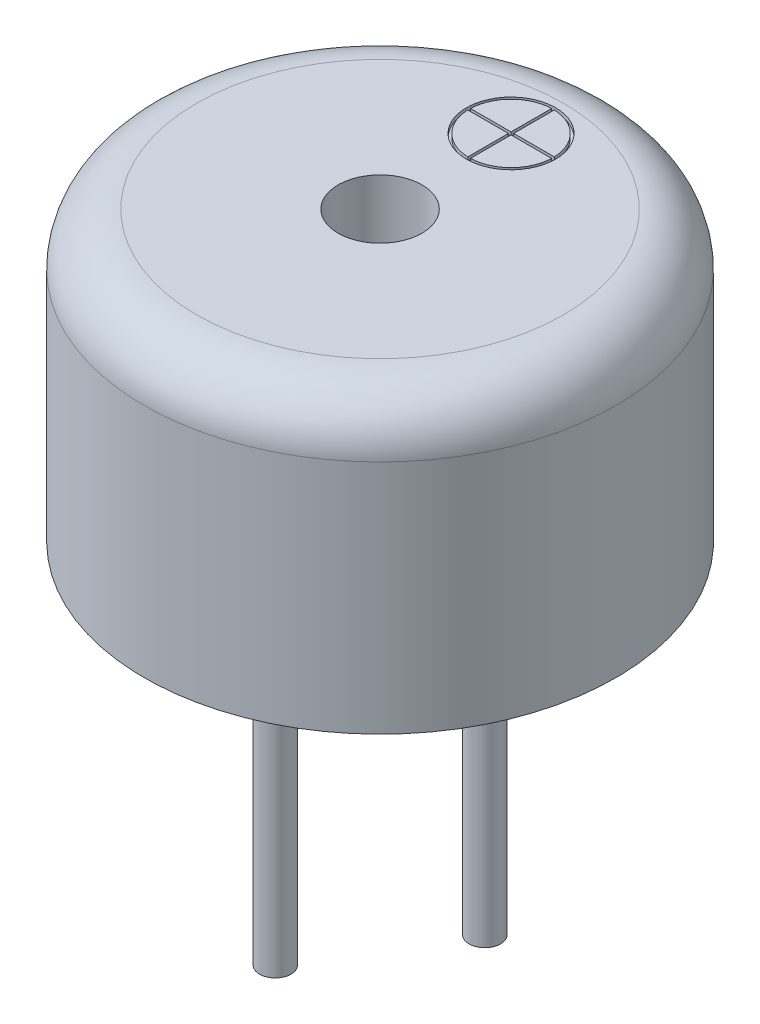
from build123d import *

# Parameters (mm, degrees)
SKETCH2_R               = 0.3
LEADS_DEPTH             = 7.5
LEADS_2_DEPTH           = 7.5
SKETCH3_R               = 0.3
CUT_EXTRUDE1_DEPTH      = 1.5
SKETCH4_R               = 0.8
CUT_EXTRUDE2_DEPTH      = 2.5
SKETCH6_R               = 0.8509
SKETCH6_R_2             = 0.8001
SKETCH6_W               = 0.0508
SKETCH6_H               = 1.651
SKETCH6_W_2             = 1.651
SKETCH6_H_2             = 0.0508
CUT_EXTRUDE_THIN1_DEPTH = 0.0762


with BuildPart() as part:
    # Sketch1 → Body (revolve)
    with BuildSketch(Plane.XY):
        with BuildLine():
            Line((-4.5, 0), (-4.5, 4.5))
            ThreePointArc((-4.5, 4.5), (-4.207106781, 5.207106781), (-3.5, 5.5))
            Line((-3.5, 5.5), (0, 5.5))
            Line((0, 5.5), (0, 0))
            Line((0, 0), (-4.5, 0))
        make_face()
    revolve(axis=Axis((0, 0, 0), (0, 1, 0)))

    # Sketch4 → Cut-Extrude2 (cut)
    with BuildSketch(Plane(origin=(0, 5.5, 0), x_dir=(1, 0, 0), z_dir=(0, 1, 0))):
        Circle(SKETCH4_R)
    extrude(amount=-CUT_EXTRUDE2_DEPTH, mode=Mode.SUBTRACT)

    # Sketch6 → Cut-Extrude-Thin1 (cut)
    with BuildSketch(Plane(origin=(0, 5.5, 0), x_dir=(1, 0, 0), z_dir=(0, 1, 0))):
        with Locations((0, 2.5)):
            Circle(SKETCH6_R)
        with Locations((0, 2.5)):
            Circle(SKETCH6_R_2, mode=Mode.SUBTRACT)
        with Locations((0, 2.5)):
            Rectangle(SKETCH6_W, SKETCH6_H)
        with Locations((0, 2.5)):
            Rectangle(SKETCH6_W_2, SKETCH6_H_2)
    extrude(amount=-CUT_EXTRUDE_THIN1_DEPTH, mode=Mode.SUBTRACT)


with BuildPart() as body_2:
    # Sketch2 → Leads (new body)
    with BuildSketch(Plane.XZ):
        with Locations((0, 2)):
            Circle(SKETCH2_R)
    extrude(amount=LEADS_DEPTH)

    # Sketch3 → Cut-Extrude1 (cut)
    with BuildSketch(Plane.XZ.offset(7.5)):
        with Locations((0, 2)):
            Circle(SKETCH3_R)
    extrude(amount=-CUT_EXTRUDE1_DEPTH, mode=Mode.SUBTRACT)


with BuildPart() as body_3:
    # Sketch2 → Leads 2 (new body)
    with BuildSketch(Plane.XZ):
        with Locations((0, -2)):
            Circle(SKETCH2_R)
    extrude(amount=LEADS_2_DEPTH)


solid = Compound([part.part, body_2.part, body_3.part])
